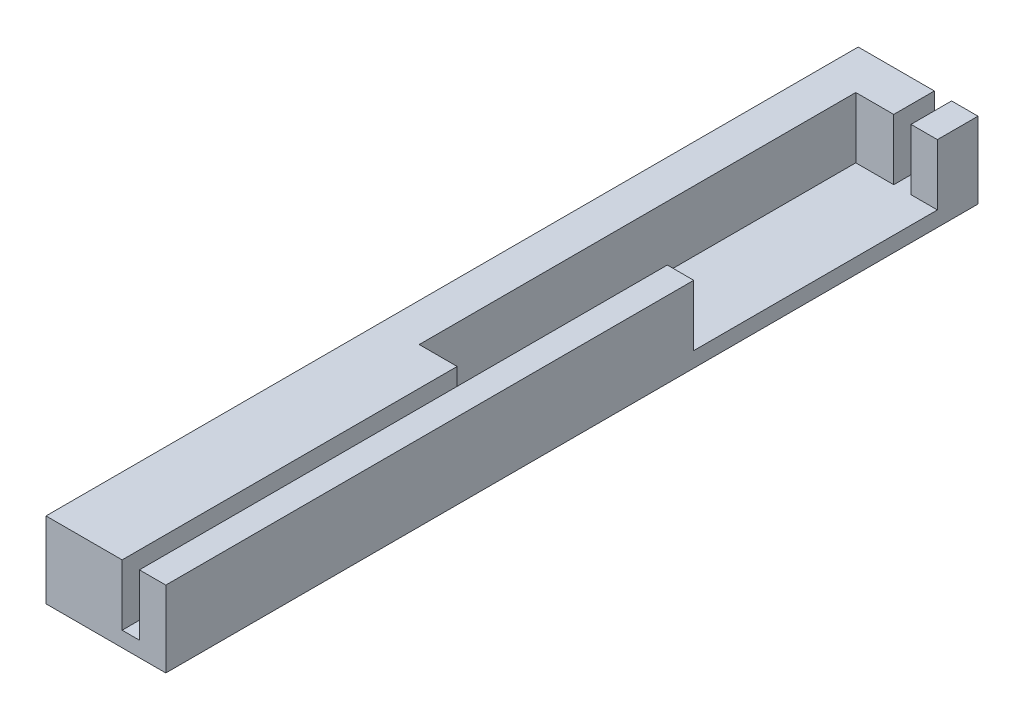
from build123d import *

# Parameters (mm, degrees)
SKETCH1_W           = 11.8
SKETCH1_H           = 80
BOSS_EXTRUDE1_DEPTH = 1.5
SKETCH2_W           = 7.5
SKETCH2_H           = 80
SKETCH2_W_2         = 2.6
BOSS_EXTRUDE2_DEPTH = 6
SKETCH3_W           = 3.738034865
SKETCH3_H           = 43
SKETCH3_W_2         = 2.6
SKETCH3_H_2         = 24
CUT_EXTRUDE1_DEPTH  = 6


with BuildPart() as part:
    # Sketch1 → Boss-Extrude1 (new body)
    with BuildSketch(Plane(origin=(0, 0, 0), x_dir=(1, 0, 0), z_dir=(0, 1, 0))):
        with Locations((2.138034865, -38.013787639)):
            Rectangle(SKETCH1_W, SKETCH1_H)
    extrude(amount=BOSS_EXTRUDE1_DEPTH)

    # Sketch2 → Boss-Extrude2 (add)
    with BuildSketch(Plane(origin=(0, 1.5, 0), x_dir=(1, 0, 0), z_dir=(0, 1, 0))):
        with Locations((-0.011965135, -38.013787639)):
            Rectangle(SKETCH2_W, SKETCH2_H)
        with Locations((6.738034865, -38.013787639)):
            Rectangle(SKETCH2_W_2, SKETCH2_H)
    extrude(amount=BOSS_EXTRUDE2_DEPTH)

    # Sketch3 → Cut-Extrude1 (cut)
    with BuildSketch(Plane(origin=(0, 7.5, 0), x_dir=(1, 0, 0), z_dir=(0, 1, 0))):
        with Locations((1.869017433, -23.513787639)):
            Rectangle(SKETCH3_W, SKETCH3_H)
        with Locations((6.738034865, -14.013787639)):
            Rectangle(SKETCH3_W_2, SKETCH3_H_2)
    extrude(amount=-CUT_EXTRUDE1_DEPTH, mode=Mode.SUBTRACT)


solid = part.part
